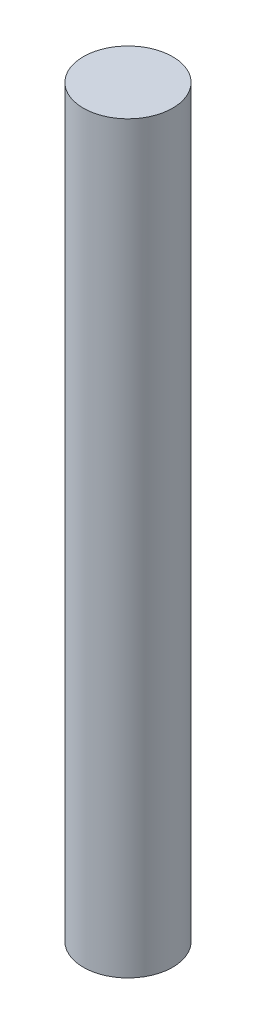
from build123d import *

# Parameters (mm, degrees)
SKETCH1_R           = 3
BOSS_EXTRUDE1_DEPTH = 50
CUT_EXTRUDE1_DEPTH  = 5


with BuildPart() as part:
    # Sketch1 → Boss-Extrude1 (new body)
    with BuildSketch(Plane(origin=(0, 0, 0), x_dir=(1, 0, 0), z_dir=(0, 1, 0))):
        Circle(SKETCH1_R)
    extrude(amount=BOSS_EXTRUDE1_DEPTH)

    # Sketch2 → Cut-Extrude1 (cut)
    with BuildSketch(Plane.XZ):
        with BuildLine():
            Line((-2.236067977, -2), (2.236067977, -2))
            ThreePointArc((2.236067977, -2), (0, -3), (-2.236067977, -2))
        make_face()
    extrude(amount=-CUT_EXTRUDE1_DEPTH, mode=Mode.SUBTRACT)


solid = part.part
